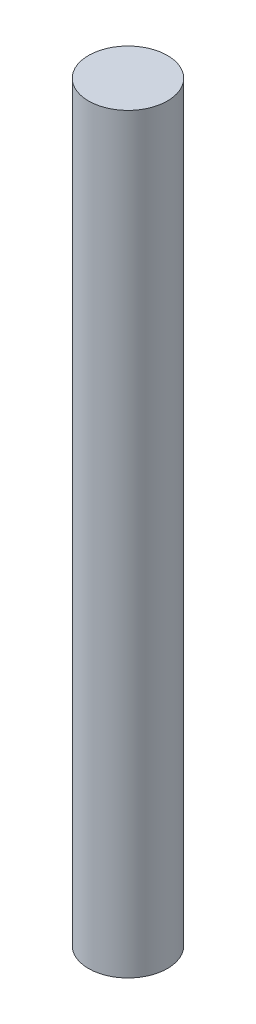
from build123d import *

# Parameters (mm, degrees)
SKETCH1_R           = 2
BOSS_EXTRUDE1_DEPTH = 38.1


with BuildPart() as part:
    # Sketch1 → Boss-Extrude1 (new body)
    with BuildSketch(Plane(origin=(0, 0, 0), x_dir=(1, 0, 0), z_dir=(0, 1, 0))):
        with Locations(Location((0, 0, 0), (0, 0, 270))):  # turned: the seam where the file's is
            Circle(SKETCH1_R)
    extrude(amount=BOSS_EXTRUDE1_DEPTH)


solid = part.part
